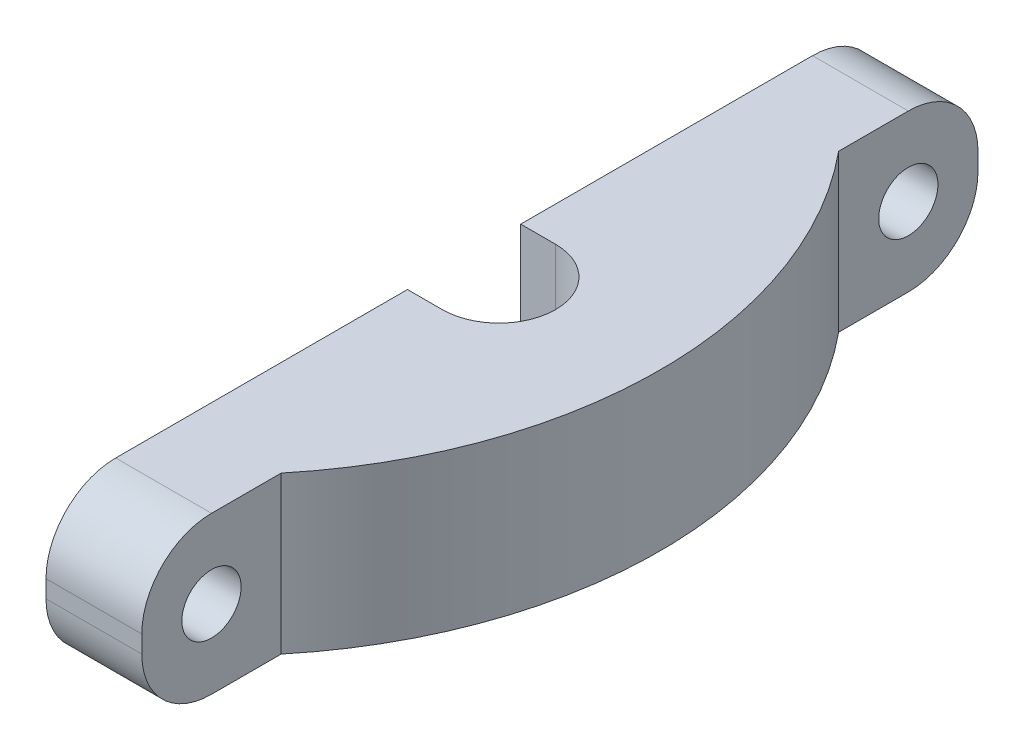
from build123d import *

# Parameters (mm, degrees)
BOSS_EXTRUDE1_DEPTH  = 11.25
CUT_EXTRUDE1_DEPTH   = 10
M3_CLEARANCE_HOLE1_D = 3.4
SKETCH7_W            = 5.75
SKETCH7_H            = 4
CUT_EXTRUDE2_DEPTH   = 10


with BuildPart() as part:
    # Sketch1 → Boss-Extrude1 (new body)
    with BuildSketch(Plane(origin=(0, 0, 0), x_dir=(0, 0, -1), z_dir=(1, 0, 0))):
        with BuildLine():
            Line((-24, 0.5), (-24, -0.5))
            ThreePointArc((-24, -0.5), (-22.828427125, -3.328427125), (-20, -4.5))
            Line((-20, -4.5), (20, -4.5))
            ThreePointArc((20, -4.5), (22.828427125, -3.328427125), (24, -0.5))
            Line((24, -0.5), (24, 0.5))
            ThreePointArc((24, 0.5), (22.828427125, 3.328427125), (20, 4.5))
            Line((20, 4.5), (-20, 4.5))
            ThreePointArc((-20, 4.5), (-22.828427125, 3.328427125), (-24, 0.5))
        make_face()
    extrude(amount=BOSS_EXTRUDE1_DEPTH)

    # Sketch2 → Cut-Extrude1 (cut, through all)
    with BuildSketch(Plane(origin=(0, -4.5, 0), x_dir=(-1, 0, 0), z_dir=(0, -1, 0))):
        with BuildLine():
            Line((-2, -3.25), (0, -3.25))
            Line((0, -3.25), (0, 3.25))
            Line((0, 3.25), (-2, 3.25))
            ThreePointArc((-2, 3.25), (-5.25, 0), (-2, -3.25))
        make_face()
    extrude(amount=-CUT_EXTRUDE1_DEPTH, mode=Mode.SUBTRACT)

    # M3 Clearance Hole1 (through all)
    with Locations(Plane(origin=(11.25, 0, 0), x_dir=(0, 0, -1), z_dir=(1, 0, 0))):
        with Locations((-20, 0), (20, 0)):
            Hole(M3_CLEARANCE_HOLE1_D / 2)

    # Sketch7 → Cut-Extrude2 (cut, through all)
    with BuildSketch(Plane(origin=(0, -4.5, 0), x_dir=(-1, 0, 0), z_dir=(0, -1, 0))):
        with Locations((-8.375, -22)):
            Rectangle(SKETCH7_W, SKETCH7_H)
        with BuildLine():
            Line((-11.25, -20), (-5.5, -20))
            Line((-5.5, -20), (-5.5, -16))
            ThreePointArc((-5.5, -16), (-9.768861754, -8.500919068), (-11.25, 0))
            Line((-11.25, 0), (-11.25, -20))
        make_face()
        with BuildLine():
            Line((-11.25, 20), (-11.25, 0))
            ThreePointArc((-11.25, 0), (-9.768861754, 8.500919068), (-5.5, 16))
            Line((-5.5, 16), (-5.5, 20))
            Line((-5.5, 20), (-11.25, 20))
        make_face()
        with Locations((-8.375, 22)):
            Rectangle(SKETCH7_W, SKETCH7_H)
    extrude(amount=-CUT_EXTRUDE2_DEPTH, mode=Mode.SUBTRACT)


solid = part.part
